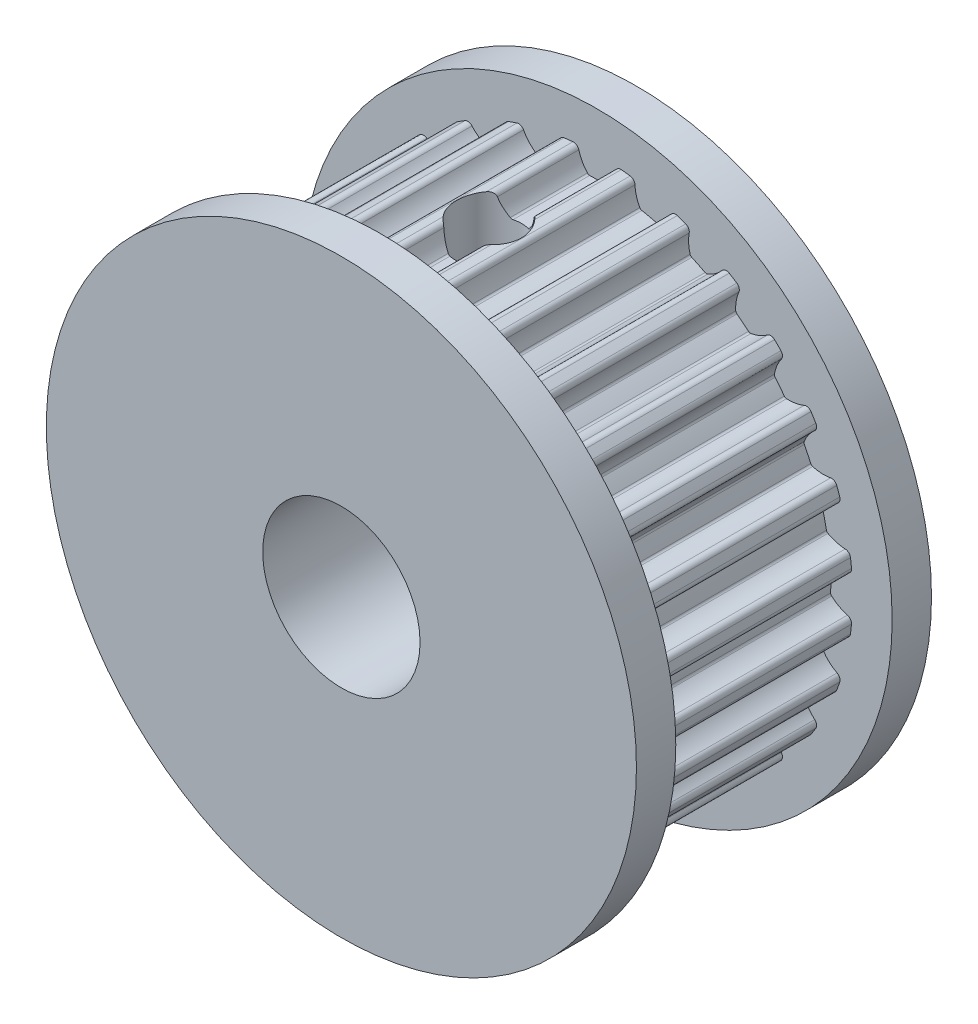
from build123d import *

# Parameters (mm, degrees)
SKETCH_1_R               = 12.99
EXTRUDE_1_DEPTH          = 5.5
CUT_EXTRUDE_START        = -12
CUT_EXTRUDE_1_DEPTH      = 13
PATTERN_CIRCULAR_1_COUNT = 28
SKETCH_3_R               = 15
EXTRUDE_2_DEPTH          = 2
SKETCH_4_R               = 4
CUT_EXTRUDE_2_DEPTH      = 16
SKETCH_6_W               = 1.65
SKETCH_6_H               = 15
PATTERN_CIRCULAR_2_COUNT = 2
PATTERN_CIRCULAR_2_ANGLE = 90


with BuildPart() as part:
    # 草圖1 → 填料-伸長1 (new body, symmetric)
    with BuildSketch(Plane.XY):
        Circle(SKETCH_1_R)
    extrude(amount=EXTRUDE_1_DEPTH, both=True)

    # 草圖2 → 除料-伸長1 (cut)
    with BuildSketch(Plane.XY.offset(5.5).offset(CUT_EXTRUDE_START)):
        with BuildLine():
            Line((-70.048095585, 6.398480172), (-1.227668901, 12.931857139))
            ThreePointArc((-1.227668901, 12.931857139), (-1.041836125, 12.883330091), (-0.930990124, 12.726480294))
            ThreePointArc((-0.930990124, 12.726480294), (-0.759471272, 12.299418395), (-0.493772121, 11.923646466))
            ThreePointArc((-0.493772121, 11.923646466), (-0.441100842, 11.885966255), (-0.377453975, 11.874002211))
            ThreePointArc((-0.377453975, 11.874002211), (0, 11.88), (0.377453975, 11.874002211))
            ThreePointArc((0.377453975, 11.874002211), (0.441100842, 11.885966255), (0.493772121, 11.923646466))
            ThreePointArc((0.493772121, 11.923646466), (0.759471272, 12.299418395), (0.930990124, 12.726480294))
            ThreePointArc((0.930990124, 12.726480294), (1.041836125, 12.883330091), (1.227668901, 12.931857139))
            Line((1.227668901, 12.931857139), (70.048095585, 6.398480172))
            Line((70.048095585, 6.398480172), (70.048095585, 144.65817992))
            Line((70.048095585, 144.65817992), (-70.048095585, 144.65817992))
            Line((-70.048095585, 144.65817992), (-70.048095585, 6.398480172))
        make_face()
    cut_extrude_1 = extrude(amount=CUT_EXTRUDE_1_DEPTH, mode=Mode.SUBTRACT)

    # 環狀複製排列1: 除料-伸長1 ×28 about axis
    pattern_circular_1_axis = Axis((0, 0, 5.5), (0, 0, 1))
    for i in range(1, PATTERN_CIRCULAR_1_COUNT):
        add(cut_extrude_1.rotate(pattern_circular_1_axis, i * 360 / PATTERN_CIRCULAR_1_COUNT), mode=Mode.SUBTRACT)

    # 草圖3 → 填料-伸長2 (add)
    with BuildSketch(Plane.XY.offset(5.5)):
        Circle(SKETCH_3_R)
    extrude_2 = extrude(amount=EXTRUDE_2_DEPTH)

    # 鏡射1: 填料-伸長2 across plane
    add(extrude_2.mirror(Plane.XY))

    # 草圖4 → 除料-伸長2 (cut, through all)
    with BuildSketch(Plane.XY.offset(7.5)):
        Circle(SKETCH_4_R)
    extrude(amount=-CUT_EXTRUDE_2_DEPTH, mode=Mode.SUBTRACT)

    # 草圖6 → M4x0.7 螺紋孔1 (revolve, cut)
    with BuildSketch(Plane(origin=(0, 0, 0), x_dir=(0, 0, -1), z_dir=(1, 0, 0))):
        with Locations((0.825, 7.5)):
            Rectangle(SKETCH_6_W, SKETCH_6_H)
    m4x0_7_1 = revolve(axis=Axis((0, -6.35, 0), (0, 1, 0)), mode=Mode.SUBTRACT)

    # 環狀複製排列2: M4x0.7 螺紋孔1 ×2 about axis
    pattern_circular_2_axis = Axis((0, 0, 7.5), (0, 0, 1))
    for i in range(1, PATTERN_CIRCULAR_2_COUNT):
        add(m4x0_7_1.rotate(pattern_circular_2_axis, i * PATTERN_CIRCULAR_2_ANGLE / (PATTERN_CIRCULAR_2_COUNT - 1)), mode=Mode.SUBTRACT)


solid = part.part
